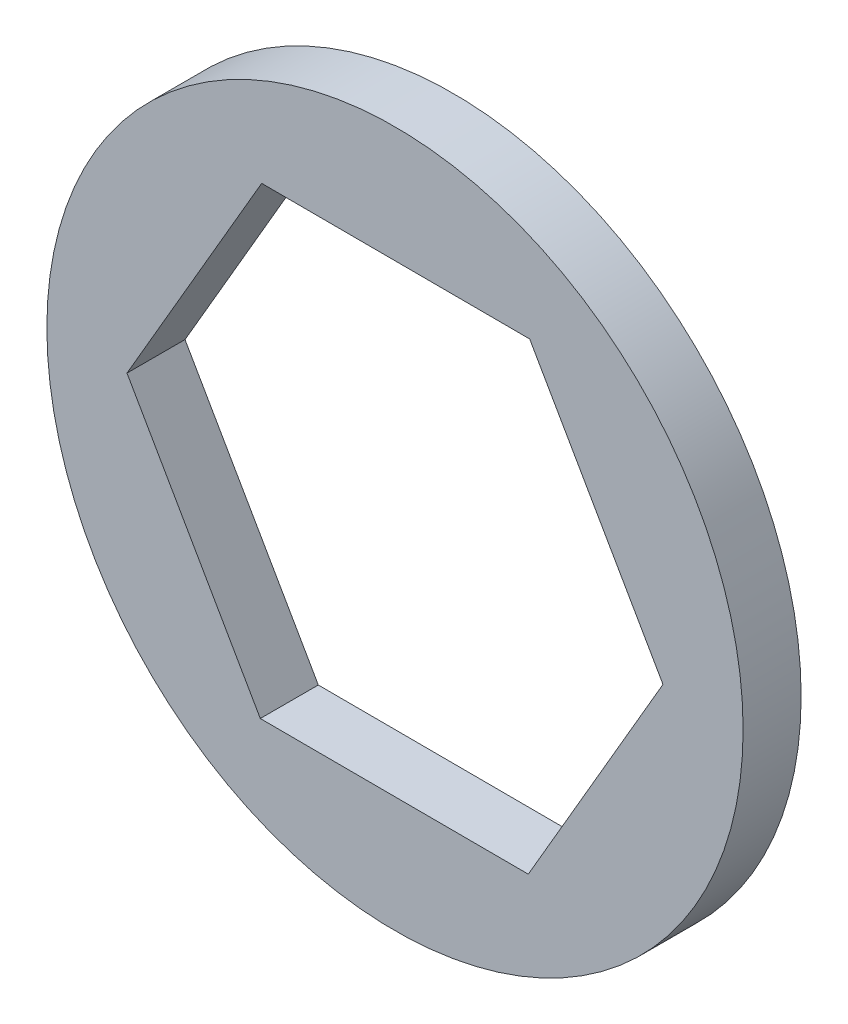
from build123d import *

# Parameters (mm, degrees)
SKETCH1_R           = 9.525
BOSS_EXTRUDE1_DEPTH = 1.5875


with BuildPart() as part:
    # Sketch1 → Boss-Extrude1 (new body)
    with BuildSketch(Plane.XY):
        Circle(SKETCH1_R)
        Polygon((3.64699361, -6.361035367), (7.332315027, -0.022128569), (3.685321417, 6.338906797), (-3.64699361, 6.361035367), (-7.332315027, 0.022128569), (-3.685321417, -6.338906797), align=None, mode=Mode.SUBTRACT)
    extrude(amount=BOSS_EXTRUDE1_DEPTH)


solid = part.part
